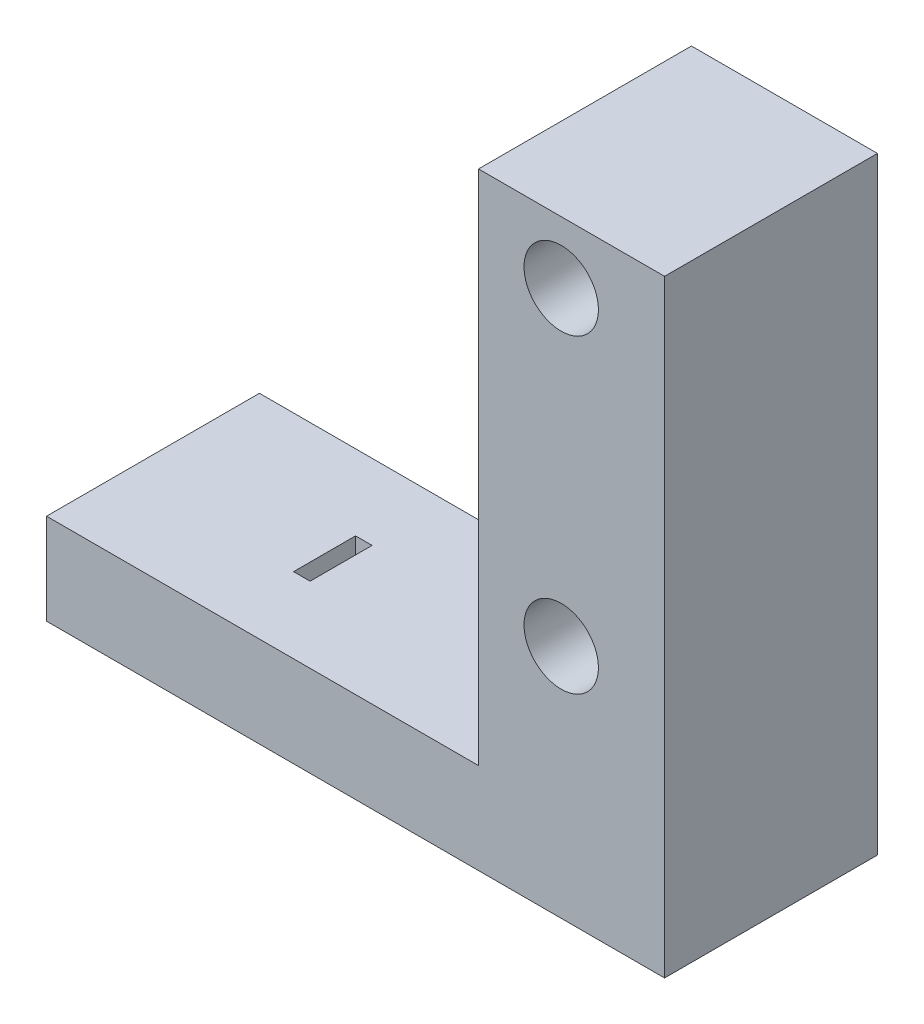
from build123d import *

# Parameters (mm, degrees)
SKETCH1_W            = 29.9
SKETCH1_H            = 10.3
SKETCH1_R            = 2.4
BOSS_EXTRUDE1_DEPTH  = 30
BOSS_EXTRUDE3_START  = -2
SKETCH4_W            = 29.9
SKETCH4_H            = 10.3
BOSS_EXTRUDE3_DEPTH  = 28
SKETCH2_W            = 20.9
SKETCH2_H            = 25
CUT_EXTRUDE1_DEPTH   = 11.3
SKETCH3_W            = 0.8
SKETCH3_H            = 3
CUT_EXTRUDE2_DEPTH   = 31
M3_CLEARANCE_HOLE1_D = 3.6
SKETCH7_W            = 1.2265006
SKETCH7_H            = 3
SKETCH7_W_2          = 1.1265006
CUT_EXTRUDE3_DEPTH   = 2
CUT_EXTRUDE4_DEPTH   = 2
CHAMFER1_SIZE        = 0.6


with BuildPart() as part:
    # Sketch1 → Boss-Extrude1 (new body)
    with BuildSketch(Plane(origin=(0, 0, 0), x_dir=(1, 0, 0), z_dir=(0, 1, 0))):
        with Locations((-5.3, 0)):
            Rectangle(SKETCH1_W, SKETCH1_H)
        Circle(SKETCH1_R, mode=Mode.SUBTRACT)
        with Locations((-14.25, 0)):
            Circle(SKETCH1_R, mode=Mode.SUBTRACT)
    extrude(amount=BOSS_EXTRUDE1_DEPTH)

    # Sketch4 → Boss-Extrude3 (add)
    with BuildSketch(Plane.XZ.offset(BOSS_EXTRUDE3_START)):
        with Locations((-5.3, 0)):
            Rectangle(SKETCH4_W, SKETCH4_H)
    extrude(amount=-BOSS_EXTRUDE3_DEPTH)

    # Sketch2 → Cut-Extrude1 (cut, through all)
    with BuildSketch(Plane.XY.offset(5.15)):
        with Locations((-9.8, 17.5)):
            Rectangle(SKETCH2_W, SKETCH2_H)
    extrude(amount=-CUT_EXTRUDE1_DEPTH, mode=Mode.SUBTRACT)

    # Sketch3 → Cut-Extrude2 (cut, through all)
    with BuildSketch(Plane.XZ):
        with Locations((-11.55, 0)):
            Rectangle(SKETCH3_W, SKETCH3_H)
        with Locations((-2.6, 0)):
            Rectangle(SKETCH3_W, SKETCH3_H)
    extrude(amount=-CUT_EXTRUDE2_DEPTH, mode=Mode.SUBTRACT)

    # M3 Clearance Hole1 (through all)
    with Locations(Plane.XY.offset(5.15)):
        with Locations((4.65, 12), (4.65, 27)):
            Hole(M3_CLEARANCE_HOLE1_D / 2)

    # Sketch7 → Cut-Extrude3 (cut)
    with BuildSketch(Plane.XZ):
        with Locations((-11.7632503, 0)):
            Rectangle(SKETCH7_W, SKETCH7_H)
        with Locations((-2.4367497, 0)):
            Rectangle(SKETCH7_W_2, SKETCH7_H)
    extrude(amount=-CUT_EXTRUDE3_DEPTH, mode=Mode.SUBTRACT)

    # Sketch8 → Cut-Extrude4 (cut)
    with BuildSketch(Plane.XZ):
        Polygon((-15.635640646, 2.4), (-17.021281292, 0), (-15.635640646, -2.4), (-12.864359354, -2.4), (-11.478718708, 0), (-12.864359354, 2.4), align=None)
        Polygon((1.385640646, 2.4), (-1.385640646, 2.4), (-2.771281292, 0), (-1.385640646, -2.4), (1.385640646, -2.4), (2.771281292, 0), align=None)
    extrude(amount=-CUT_EXTRUDE4_DEPTH, mode=Mode.SUBTRACT)

    # Chamfer1
    chamfer1_edges = [part.edges().sort_by_distance(p)[0] for p in [
        (-11.747372056, 0, -1.5),
        (-2.452627944, 0, 1.5),
        (-12.604551733, 0, 1.95),
        (-14.25, 0, 2.4),
        (-16.328460969, 0, 1.2),
        (-16.328460969, 0, -1.2),
        (-14.25, 0, -2.4),
        (-12.604551733, 0, -1.95),
        (-1.645448267, 0, 1.95),
        (0, 0, 2.4),
        (2.078460969, 0, 1.2),
        (2.078460969, 0, -1.2),
        (0, 0, -2.4),
        (-1.645448267, 0, -1.95),
        (-5.3, 0, -5.15),
        (9.65, 0, 0),
        (-5.3, 0, 5.15),
        (-20.25, 0, 0),
        (-11.15, 0, 0),
        (-11.747372056, 0, 1.5),
        (-3, 0, 0),
        (-2.452627944, 0, -1.5),
    ]]
    chamfer(chamfer1_edges, length=CHAMFER1_SIZE)


solid = part.part
